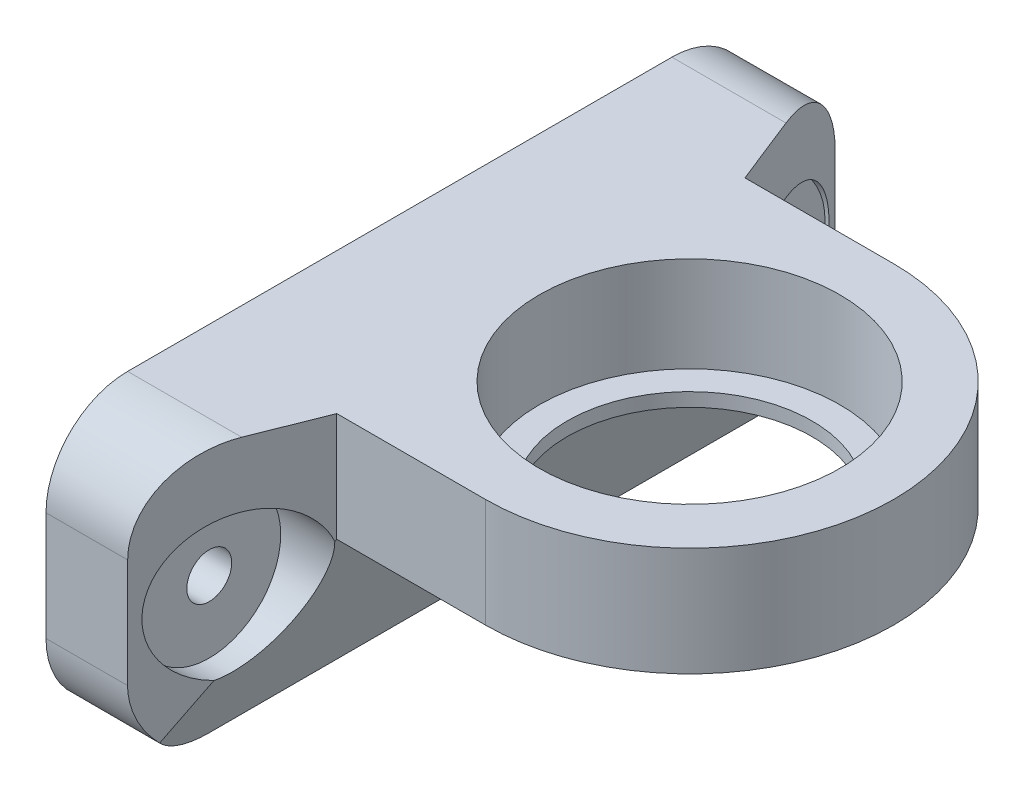
from build123d import *

# Parameters (mm, degrees)
RESSALTO_EXTRUS_O1_DEPTH   = 60
CORTE_EXTRUS_O1_DEPTH      = 79.390050389
CORTE_EXTRUS_O1_DEPTH_BACK = 79.390050389
ESBO_O2_R                  = 9
ESBO_O3_R                  = 1.65
CORTE_EXTRUS_O2_DEPTH      = 70.668429005
ESBO_O4_R                  = 11.05
CORTE_EXTRUS_O3_DEPTH      = 7
CORTE_EXTRUS_O5_START      = 6
ESBO_O7_R                  = 5.25
CORTE_EXTRUS_O5_DEPTH      = 10
ESBO_O7_2_R                = 5.25
CORTE_EXTRUS_O7_DEPTH      = 1
FILETE1_R                  = 6


with BuildPart() as part:
    # Esboço1 → Ressalto-extrusão1 (new body)
    with BuildSketch(Plane.XY):
        Polygon((0, 0), (6, 0), (10.367642811, 12), (49, 12), (49, 20), (0, 20), align=None)
    extrude(amount=RESSALTO_EXTRUS_O1_DEPTH)

    # Esboço2 → Corte-extrusão1 (cut, two sides: drawn at the far end of the back side and taken through both)
    with BuildSketch(Plane.XZ.offset(-12).offset(-CORTE_EXTRUS_O1_DEPTH_BACK)):
        with Locations((21.3, 30)):
            Circle(ESBO_O2_R)
        with BuildLine():
            Line((21.3, 15), (10.367642811, 15))
            Line((10.367642811, 15), (6, 4))
            Line((6, 4), (0, 4))
            Line((0, 4), (0, 0))
            Line((0, 0), (49, 0))
            Line((49, 0), (49, 60))
            Line((49, 60), (0, 60))
            Line((0, 60), (0, 56))
            Line((0, 56), (6, 56))
            Line((6, 56), (10.367642811, 45))
            Line((10.367642811, 45), (21.3, 45))
            ThreePointArc((21.3, 45), (36.3, 30), (21.3, 15))
        make_face()
    extrude(amount=CORTE_EXTRUS_O1_DEPTH + CORTE_EXTRUS_O1_DEPTH_BACK, mode=Mode.SUBTRACT)

    # Esboço3 → Corte-extrusão2 (cut, through all)
    with BuildSketch(Plane.ZY):
        with Locations((50, 10)):
            Circle(ESBO_O3_R)
        with Locations((10, 10)):
            Circle(ESBO_O3_R)
    extrude(amount=-CORTE_EXTRUS_O2_DEPTH, mode=Mode.SUBTRACT)

    # Esboço4 → Corte-extrusão3 (cut)
    with BuildSketch(Plane(origin=(0, 20, 0), x_dir=(1, 0, 0), z_dir=(0, 1, 0))):
        with Locations((21.3, -30)):
            Circle(ESBO_O4_R)
    extrude(amount=-CORTE_EXTRUS_O3_DEPTH, mode=Mode.SUBTRACT)

    # Esboço7 → Corte-extrusão5 (cut)
    with BuildSketch(Plane(origin=(0, 0, 0), x_dir=(0, 0, -1), z_dir=(1, 0, 0)).offset(CORTE_EXTRUS_O5_START)):
        with Locations((-50, 10)):
            Circle(ESBO_O7_R)
        with Locations((-10, 10)):
            Circle(ESBO_O7_R)
    extrude(amount=CORTE_EXTRUS_O5_DEPTH, mode=Mode.SUBTRACT)

    # Esboço7<2> → Corte-extrusão7 (cut)
    with BuildSketch(Plane(origin=(0, 0, 0), x_dir=(0, 0, -1), z_dir=(1, 0, 0))):
        with Locations((-50, 10)):
            Circle(ESBO_O7_2_R)
        with Locations((-10, 10)):
            Circle(ESBO_O7_2_R)
    extrude(amount=CORTE_EXTRUS_O7_DEPTH, mode=Mode.SUBTRACT)

    # Filete1
    filete1_edges = [part.edges().sort_by_distance(p)[0] for p in [
        (3, 0, 4),
        (3, 20, 4),
        (3, 20, 56),
        (3, 0, 56),
    ]]
    fillet(filete1_edges, radius=FILETE1_R)


solid = part.part
